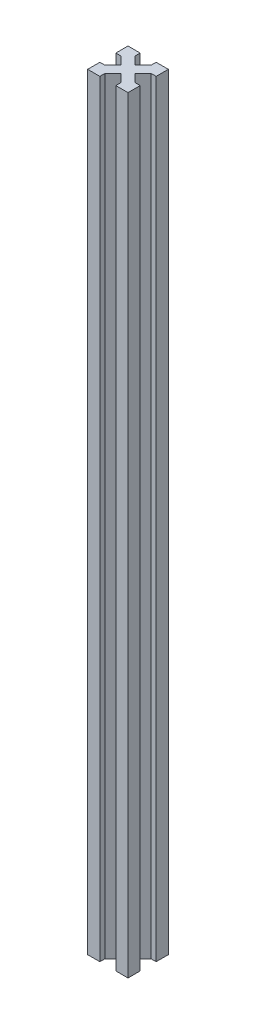
from build123d import *

# Parameters (mm, degrees)
BOSS_EXTRU_1_DEPTH = 380


with BuildPart() as part:
    # Esquisse1 → Boss.-Extru.1 (new body)
    with BuildSketch(Plane(origin=(0, 0, 0), x_dir=(1, 0, 0), z_dir=(0, 1, 0))):
        Polygon((-3.535533906, 0), (-6.035533906, 2.5), (-6.035533906, 0), align=None)
        Polygon((0, 3.535533906), (-2.5, 6.035533906), (-2.5, 2.5), (-6.035533906, 2.5), (-3.535533906, 0), (0, 0), align=None)
        Polygon((0, 6.035533906), (-2.5, 6.035533906), (0, 3.535533906), align=None)
        Polygon((-2.5, 2.5), (-2.5, 6.035533906), (-6.464466094, 10), (-10, 6.464466094), (-6.035533906, 2.5), align=None)
        Polygon((-13.964466094, 0), (-13.964466094, 2.5), (-16.464466094, 0), align=None)
        Polygon((-17.5, 2.5), (-17.5, 6.035533906), (-20, 3.535533906), (-20, 0), (-16.464466094, 0), (-13.964466094, 2.5), align=None)
        Polygon((-20, 3.535533906), (-17.5, 6.035533906), (-20, 6.035533906), align=None)
        Polygon((-10, 6.464466094), (-13.535533906, 10), (-17.5, 6.035533906), (-17.5, 2.5), (-13.964466094, 2.5), align=None)
        Polygon((-6.464466094, 10), (-10, 13.535533906), (-13.535533906, 10), (-10, 6.464466094), align=None)
        Polygon((-2.5, 13.964466094), (-2.5, 17.5), (-6.035533906, 17.5), (-10, 13.535533906), (-6.464466094, 10), align=None)
        Polygon((-6.035533906, 17.5), (-2.5, 17.5), (-2.5, 13.964466094), (0, 16.464466094), (0, 20), (-3.535533906, 20), align=None)
        Polygon((0, 16.464466094), (-2.5, 13.964466094), (0, 13.964466094), align=None)
        Polygon((-6.035533906, 20), (-6.035533906, 17.5), (-3.535533906, 20), align=None)
        Polygon((-16.464466094, 20), (-13.964466094, 17.5), (-13.964466094, 20), align=None)
        Polygon((-17.5, 17.5), (-13.964466094, 17.5), (-16.464466094, 20), (-20, 20), (-20, 16.464466094), (-17.5, 13.964466094), align=None)
        Polygon((-20, 13.964466094), (-17.5, 13.964466094), (-20, 16.464466094), align=None)
        Polygon((-10, 13.535533906), (-13.964466094, 17.5), (-17.5, 17.5), (-17.5, 13.964466094), (-13.535533906, 10), align=None)
    extrude(amount=BOSS_EXTRU_1_DEPTH)


solid = part.part
